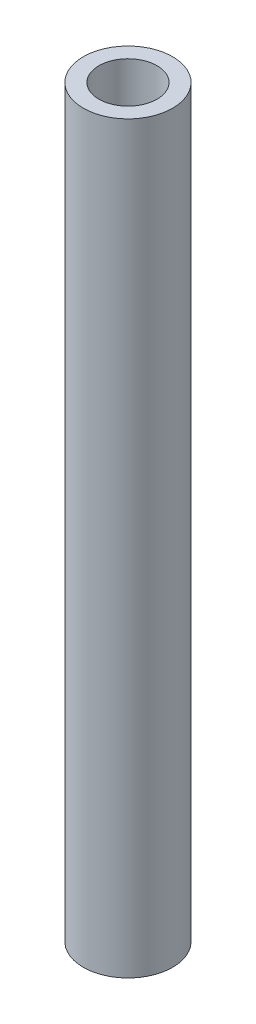
from build123d import *

# Parameters (mm, degrees)
SKETCH1_R           = 4.7625
SKETCH1_R_2         = 3.1
BOSS_EXTRUDE1_DEPTH = 79.375


with BuildPart() as part:
    # Sketch1 → Boss-Extrude1 (new body)
    with BuildSketch(Plane(origin=(0, 0, 0), x_dir=(1, 0, 0), z_dir=(0, 1, 0))):
        Circle(SKETCH1_R)
        Circle(SKETCH1_R_2, mode=Mode.SUBTRACT)
    extrude(amount=BOSS_EXTRUDE1_DEPTH)


solid = part.part
